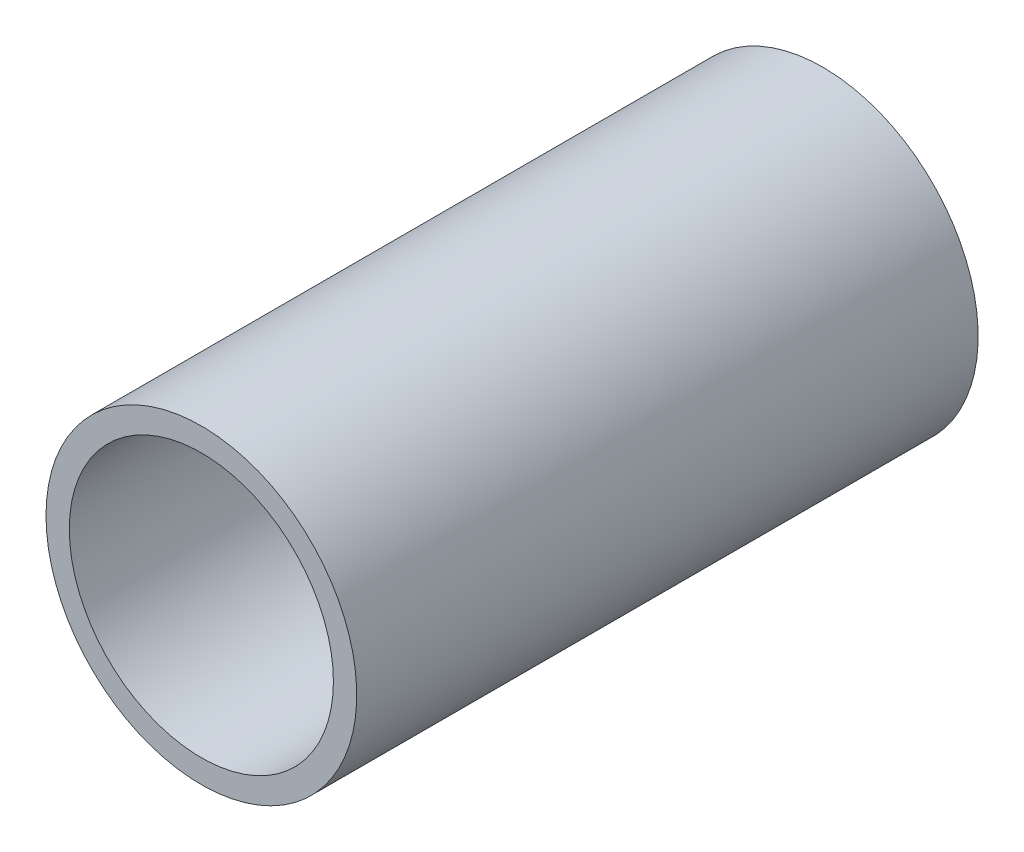
from build123d import *

# Parameters (mm, degrees)
ESQUISSE1_R        = 10
ESQUISSE1_R_2      = 8.5
BOSS_EXTRU_1_DEPTH = 40


with BuildPart() as part:
    # Esquisse1 → Boss.-Extru.1 (new body)
    with BuildSketch(Plane(origin=(0, 0, -4), x_dir=(-1, 0, 0), z_dir=(0, 0, -1))):
        with Locations((43.53806901, 71.05304224)):
            Circle(ESQUISSE1_R)
        with Locations((43.53806901, 71.05304224)):
            Circle(ESQUISSE1_R_2, mode=Mode.SUBTRACT)
    extrude(amount=BOSS_EXTRU_1_DEPTH)


solid = part.part
